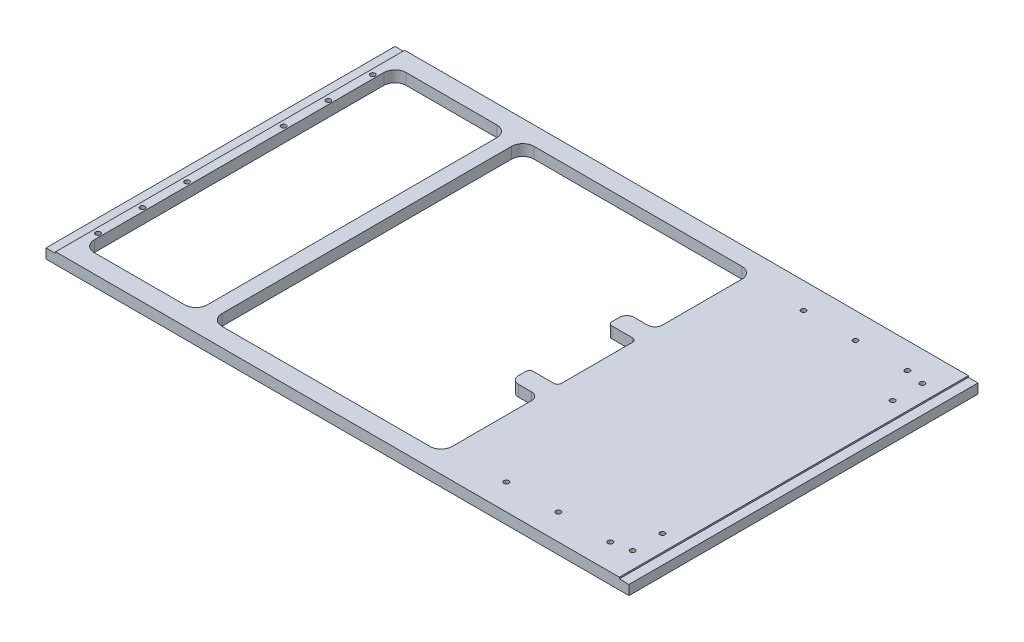
from build123d import *

# Parameters (mm, degrees)
SKETCH1_W                  = 785
SKETCH1_H                  = 470
BOSS_EXTRUDE1_DEPTH        = 15
SKETCH2_W                  = 152
SKETCH2_H                  = 420
CUT_EXTRUDE1_DEPTH         = 16
CUT_EXTRUDE2_DEPTH         = 16
FILLET1_R                  = 15
FILLET2_R                  = 10
FILLET3_R                  = 5
SKETCH5_W                  = 13
SKETCH5_H                  = 2
CUT_EXTRUDE3_DEPTH         = 471
SKETCH6_W                  = 13
SKETCH6_H                  = 2
CUT_EXTRUDE4_DEPTH         = 471
F_6_6_6_6_DIAMETER_SLOT1_D = 6.6


with BuildPart() as part:
    # Sketch1 → Boss-Extrude1 (new body)
    with BuildSketch(Plane(origin=(0, 0, 0), x_dir=(1, 0, 0), z_dir=(0, 1, 0))):
        with Locations((392.5, 235)):
            Rectangle(SKETCH1_W, SKETCH1_H)
    extrude(amount=BOSS_EXTRUDE1_DEPTH)

    # Sketch2 → Cut-Extrude1 (cut, through all)
    with BuildSketch(Plane(origin=(0, 15, 0), x_dir=(1, 0, 0), z_dir=(0, 1, 0))):
        with Locations((101, 235)):
            Rectangle(SKETCH2_W, SKETCH2_H)
    extrude(amount=-CUT_EXTRUDE1_DEPTH, mode=Mode.SUBTRACT)

    # Sketch3 → Cut-Extrude2 (cut, through all)
    with BuildSketch(Plane(origin=(0, 15, 0), x_dir=(1, 0, 0), z_dir=(0, 1, 0))):
        Polygon((197, 445), (507, 445), (507, 313), (469, 313), (469, 288), (507, 288), (507, 182), (469, 182), (469, 157), (507, 157), (507, 25), (197, 25), align=None)
    extrude(amount=-CUT_EXTRUDE2_DEPTH, mode=Mode.SUBTRACT)

    # Fillet1
    fillet1_edges = [part.edges().sort_by_distance(p)[0] for p in [
        (25, 7.5, -25),
        (25, 7.5, -445),
        (177, 7.5, -445),
        (177, 7.5, -25),
        (197, 7.5, -25),
        (197, 7.5, -445),
        (507, 7.5, -445),
        (507, 7.5, -25),
    ]]
    fillet(fillet1_edges, radius=FILLET1_R)

    # Fillet2
    fillet2_edges = [part.edges().sort_by_distance(p)[0] for p in [
        (507, 7.5, -313),
        (469, 7.5, -313),
        (469, 7.5, -157),
        (507, 7.5, -157),
    ]]
    fillet(fillet2_edges, radius=FILLET2_R)

    # Fillet3
    fillet3_edges = [part.edges().sort_by_distance(p)[0] for p in [
        (469, 7.5, -288),
        (507, 7.5, -288),
        (507, 7.5, -182),
        (469, 7.5, -182),
    ]]
    fillet(fillet3_edges, radius=FILLET3_R)

    # Sketch5 → Cut-Extrude3 (cut, through all)
    with BuildSketch(Plane.XY):
        with Locations((6.5, 14)):
            Rectangle(SKETCH5_W, SKETCH5_H)
    extrude(amount=-CUT_EXTRUDE3_DEPTH, mode=Mode.SUBTRACT)

    # Sketch6 → Cut-Extrude4 (cut, through all)
    with BuildSketch(Plane.XY):
        with Locations((778.5, 14)):
            Rectangle(SKETCH6_W, SKETCH6_H)
    extrude(amount=-CUT_EXTRUDE4_DEPTH, mode=Mode.SUBTRACT)

    # Ø6.6 (6.6) Diameter Slot1 (through all)
    with Locations(Plane(origin=(0, 0, 0), x_dir=(-1, 0, 0), z_dir=(0, -1, 0))):
        with Locations((-20, 50), (-20, 110), (-20, 170), (-20, 300), (-20, 360), (-20, 420), (-585, 435), (-655, 435), (-725, 435), (-750, 430), (-750, 390), (-750, 80), (-750, 40), (-725, 35), (-655, 35), (-585, 35)):
            Hole(F_6_6_6_6_DIAMETER_SLOT1_D / 2)


solid = part.part
